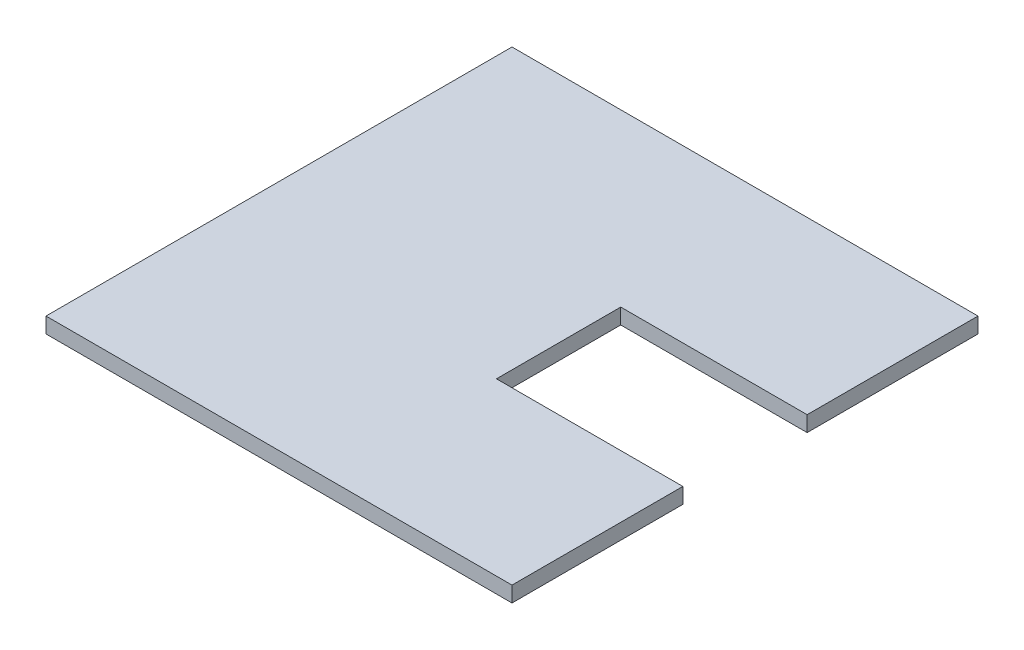
from build123d import *

# Parameters (mm, degrees)
BOSS_EXTRUDE1_DEPTH = 5


with BuildPart() as part:
    # Sketch1 → Boss-Extrude1 (new body)
    with BuildSketch(Plane(origin=(0, 0, 0), x_dir=(1, 0, 0), z_dir=(0, 1, 0))):
        Polygon((74.189235934, 110.757312246), (134.189235934, 110.757312246), (134.189235934, 165.757312246), (-15.810764066, 165.757312246), (-15.810764066, 15.757312246), (134.189235934, 15.757312246), (134.189235934, 70.757312246), (74.189235934, 70.757312246), (74.189235934, 90.757312246), align=None)
    extrude(amount=BOSS_EXTRUDE1_DEPTH)


solid = part.part
